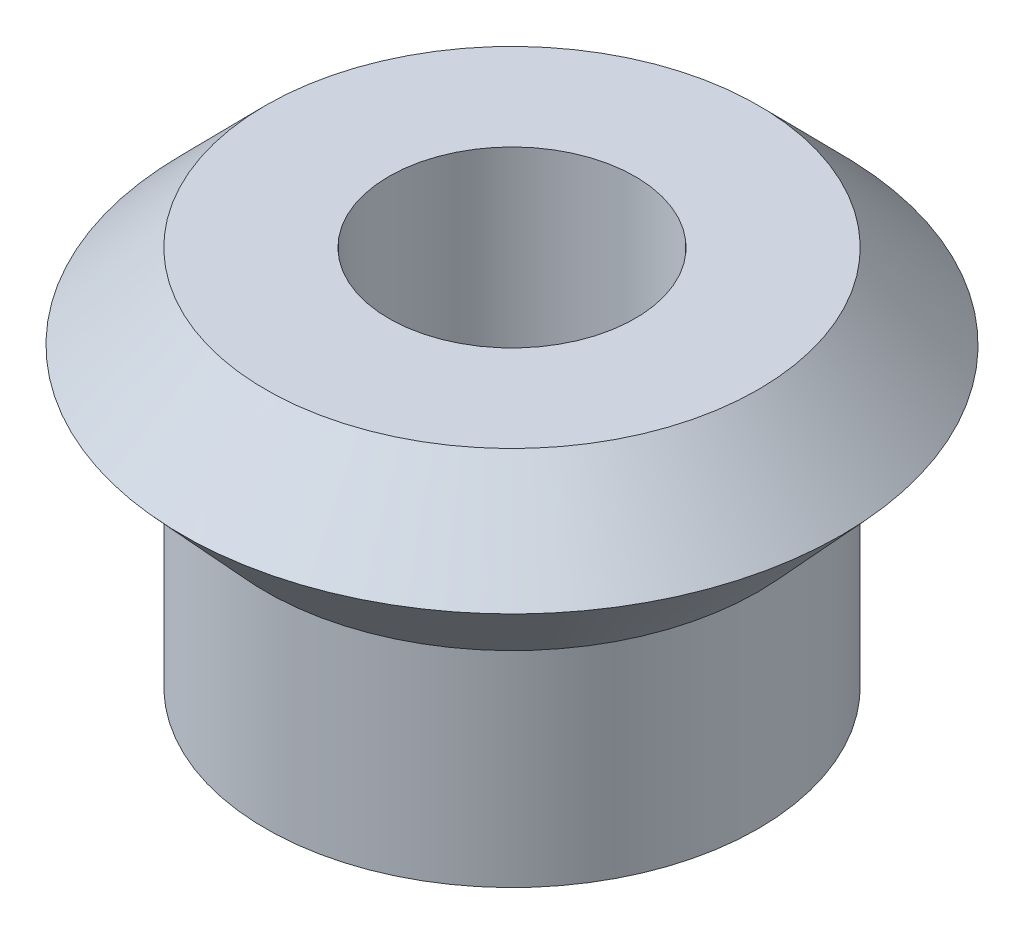
from build123d import *


with BuildPart() as part:
    # Sketch3 → Revolve1 (revolve)
    with BuildSketch(Plane.XY):
        Polygon((0, 0), (6, 0), (6, 18.53), (0, 18.53), (-4.06, 14.417736977), (0, 10), align=None)
    revolve(axis=Axis((12, 18.53, 0), (0, -1, 0)))


solid = part.part
